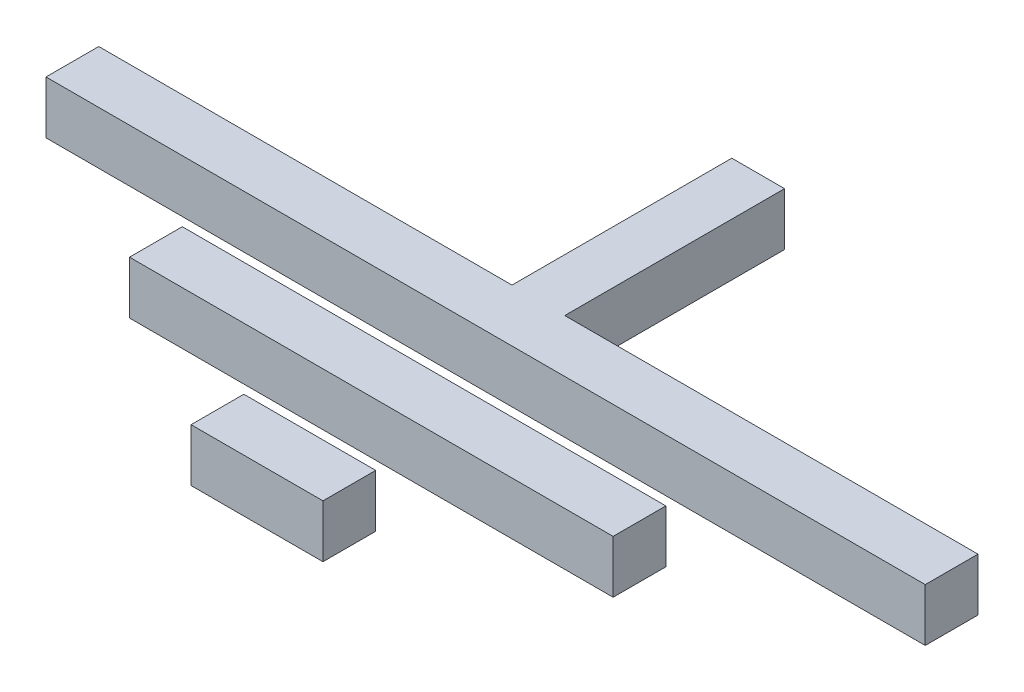
from build123d import *

# Parameters (mm, degrees)
SKETCH1_W           = 6
SKETCH1_H           = 25
SKETCH1_W_2         = 55
SKETCH1_H_2         = 6
SKETCH1_W_3         = 15
BOSS_EXTRUDE2_DEPTH = 6


with BuildPart() as part:
    # Sketch1 → Boss-Extrude2 (new body)
    with BuildSketch(Plane(origin=(0, 0, 0), x_dir=(1, 0, 0), z_dir=(0, 1, 0))):
        with Locations((5.502552118, -10.133739965)):
            Rectangle(SKETCH1_W, SKETCH1_H)
        Polygon((8.502552118, -22.633739965), (2.502552118, -22.633739965), (-44.497447882, -22.633739965), (-44.497447882, -28.633739965), (55.502552118, -28.633739965), (55.502552118, -22.633739965), align=None)
        with Locations((5.502552118, -38.633739965)):
            Rectangle(SKETCH1_W_2, SKETCH1_H_2)
        with Locations((5.502552118, -51.633739965)):
            Rectangle(SKETCH1_W_3, SKETCH1_H_2)
    extrude(amount=BOSS_EXTRUDE2_DEPTH)


solid = part.part
